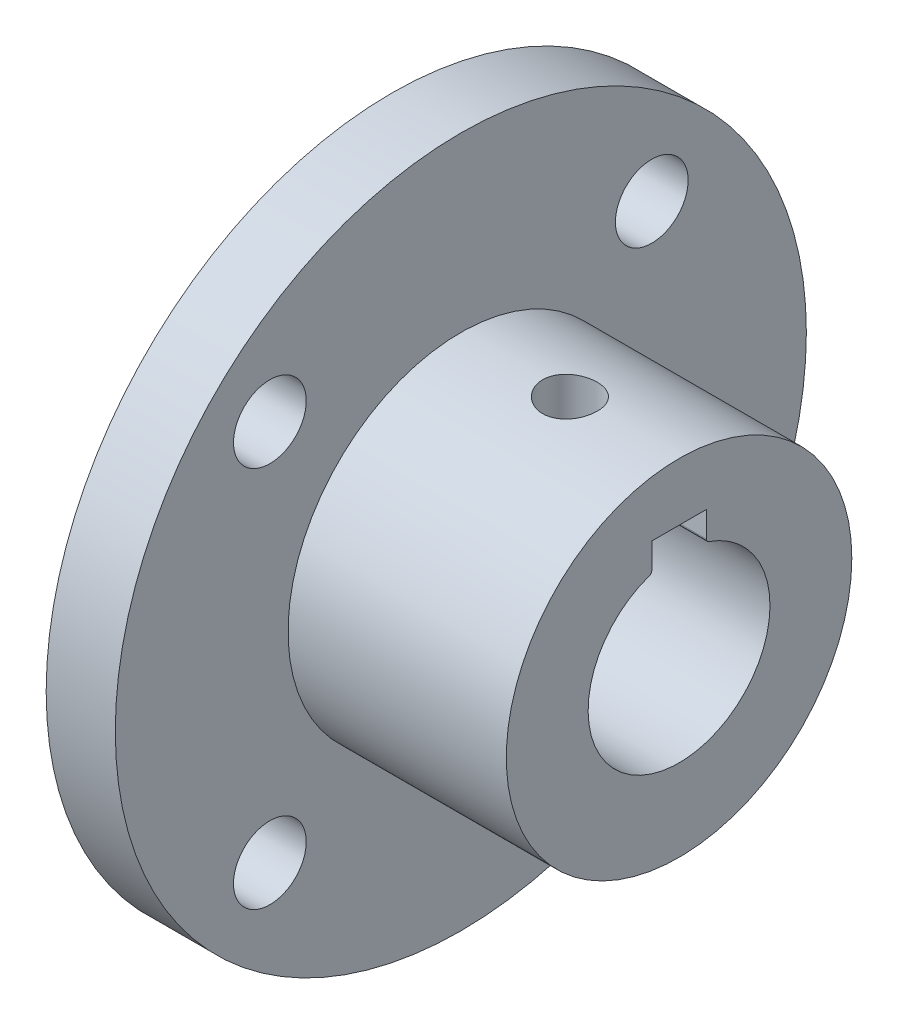
from build123d import *

# Parameters (mm, degrees)
SKETCH1_R           = 9.5
BOSS_EXTRUDE1_DEPTH = 12
SKETCH4_R           = 19
SKETCH4_R_2         = 2
BOSS_EXTRUDE3_DEPTH = 3.8
CUT_EXTRUDE2_DEPTH  = 20
SKETCH5_R           = 1.5
CUT_EXTRUDE3_DEPTH  = 5


with BuildPart() as part:
    # Sketch1 → Boss-Extrude1 (new body)
    with BuildSketch(Plane(origin=(0, 0, 0), x_dir=(0, 0, -1), z_dir=(1, 0, 0))):
        Circle(SKETCH1_R)
    extrude(amount=BOSS_EXTRUDE1_DEPTH)

    # Sketch4 → Boss-Extrude3 (add)
    with BuildSketch(Plane.ZY):
        Circle(SKETCH4_R)
        with Locations((-10.5, 10.5)):
            Circle(SKETCH4_R_2, mode=Mode.SUBTRACT)
        with Locations((10.5, 10.5)):
            Circle(SKETCH4_R_2, mode=Mode.SUBTRACT)
        with Locations((10.5, -10.5)):
            Circle(SKETCH4_R_2, mode=Mode.SUBTRACT)
        with Locations((-10.5, -10.5)):
            Circle(SKETCH4_R_2, mode=Mode.SUBTRACT)
    extrude(amount=BOSS_EXTRUDE3_DEPTH)

    # Sketch2 → Cut-Extrude2 (cut)
    with BuildSketch(Plane(origin=(12, 0, 0), x_dir=(0, 0, -1), z_dir=(1, 0, 0))):
        with BuildLine():
            Line((-1.5, 6.319696007), (1.5, 6.319696007))
            Line((1.5, 6.319696007), (1.5, 4.91426495))
            ThreePointArc((1.5, 4.91426495), (1.537093703, 4.79824108), (1.634615385, 4.72525476))
            ThreePointArc((1.634615385, 4.72525476), (0, -5), (-1.634615385, 4.72525476))
            ThreePointArc((-1.634615385, 4.72525476), (-1.537093703, 4.79824108), (-1.5, 4.91426495))
            Line((-1.5, 4.91426495), (-1.5, 6.319696007))
        make_face()
    extrude(amount=-CUT_EXTRUDE2_DEPTH, mode=Mode.SUBTRACT)

    # Sketch5 → Cut-Extrude3 (cut)
    with BuildSketch(Plane.XZ.offset(-6.319696007)):
        with Locations((6, 0)):
            Circle(SKETCH5_R)
    extrude(amount=-CUT_EXTRUDE3_DEPTH, mode=Mode.SUBTRACT)


solid = part.part
